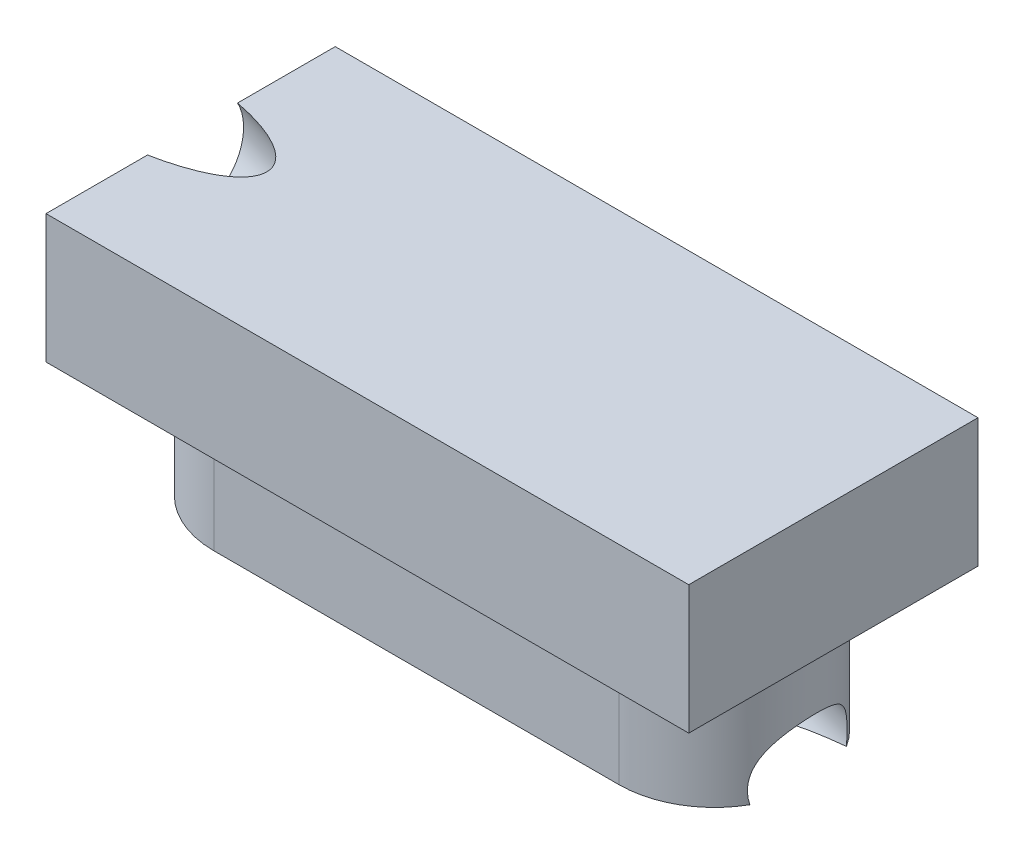
from build123d import *

# Parameters (mm, degrees)
SKETCH1_W           = 3.15
SKETCH1_H           = 1.4875
BOSS_EXTRUDE1_DEPTH = 1
SKETCH5_W           = 5
SKETCH5_H           = 2.25
BOSS_EXTRUDE2_DEPTH = 1
SKETCH4_2_R         = 0.396875


with BuildPart() as part:
    # Sketch1 → Boss-Extrude1 (new body)
    with BuildSketch(Plane(origin=(0, 0, 0), x_dir=(1, 0, 0), z_dir=(0, 1, 0))):
        with Locations((0, -0.047367461)):
            Rectangle(SKETCH1_W, SKETCH1_H)
        with BuildLine():
            Line((-1.575, -0.791117461), (-1.575, 0.696382539))
            ThreePointArc((-1.575, 0.696382539), (-2.31875, -0.047367461), (-1.575, -0.791117461))
        make_face()
        with BuildLine():
            ThreePointArc((1.575, -0.791117461), (2.31875, -0.047367461), (1.575, 0.696382539))
            Line((1.575, 0.696382539), (1.575, -0.791117461))
        make_face()
    extrude(amount=BOSS_EXTRUDE1_DEPTH)

    # Sketch5 → Boss-Extrude2 (add)
    with BuildSketch(Plane(origin=(0, 1, 0), x_dir=(1, 0, 0), z_dir=(0, 1, 0))):
        with Locations((0, -0.047367461)):
            Rectangle(SKETCH5_W, SKETCH5_H)
    extrude(amount=BOSS_EXTRUDE2_DEPTH)

    # Cut-Sweep4: sweep along a path in Sketch6
    with BuildLine(Plane.XY) as cut_sweep4_path:
        Line((2.5, 0), (-2.867631708, 1.95365817))
    # Sketch4_2 → Cut-Sweep4 (sweep, cut)
    with BuildSketch(Plane(origin=(2.5, 1, 0), x_dir=(0, 0, 1), z_dir=(-1, 0, 0))):
        with Locations((0.032314724, -1.006488934)):
            Circle(SKETCH4_2_R)
    sweep(path=cut_sweep4_path.line, mode=Mode.SUBTRACT)


solid = part.part
